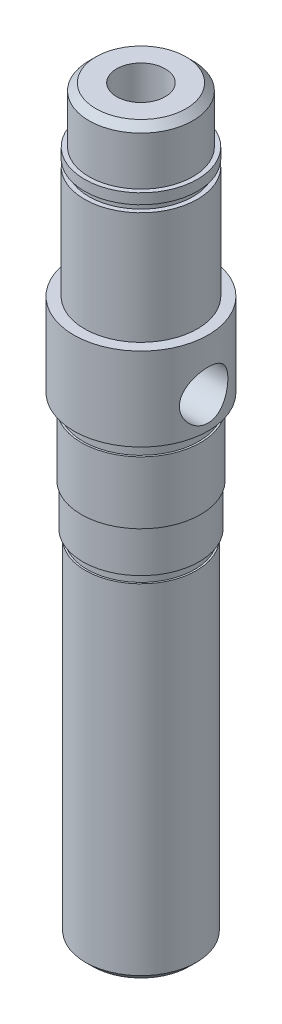
from build123d import *

# Parameters (mm, degrees)
ENL_V_START             = -5.5
ESQUISSE2_W             = 11.618950038
ESQUISSE2_H             = 44.4
ENL_V_MAT_EXTRU_1_DEPTH = 5.2
ENL_V_MAT_EXTRU_2_DEPTH = 10.7
ESQUISSE6_R             = 3.5
ENL_V_MAT_EXTRU_3_DEPTH = 120
CHANFREIN1_SIZE         = 1


with BuildPart() as part:
    # Esquisse1 → Révolution1 (revolve)
    with BuildSketch(Plane.XY):
        Polygon((0, 0), (-7, 0), (-8, 1), (-8, 50), (-7.75, 50), (-7.75, 51.3), (-8.4, 51.3), (-8.4, 57.3), (-8.6, 57.3), (-8.6, 66.3), (-8.33, 66.3), (-8.33, 68.3), (-9.7, 68.3), (-9.7, 80.3), (-8.15, 80.3), (-8.15, 96.5), (-7.5, 96.5), (-7.5, 97.5), (-8.15, 97.5), (-8.15, 99), (-7.5, 99), (-7.5, 106), (-6.5, 107), (0, 107), align=None)
    revolve(axis=Axis((0, 107, 0), (0, -1, 0)))

    # Esquisse2 → Enlèv. mat.-Extru.1 (cut, through all)
    with BuildSketch(Plane.XY.offset(ENL_V_START)):
        with Locations((0, 24.9)):
            Rectangle(ESQUISSE2_W, ESQUISSE2_H)
    extrude(amount=-ENL_V_MAT_EXTRU_1_DEPTH, mode=Mode.SUBTRACT)

    # Esquisse5 → Enlèv. mat.-Extru.2 (cut, through all)
    with BuildSketch(Plane(origin=(0, 0, 0), x_dir=(0, 0, -1), z_dir=(1, 0, 0))):
        with BuildLine():
            ThreePointArc((0, 76.3), (-3.5, 72.8), (0, 69.3))
            ThreePointArc((0, 69.3), (3.5, 72.8), (0, 76.3))
        make_face()
    extrude(amount=ENL_V_MAT_EXTRU_2_DEPTH, mode=Mode.SUBTRACT)

    # Esquisse6 → Enlèv. mat.-Extru.3 (cut)
    with BuildSketch(Plane.XZ):
        Circle(ESQUISSE6_R)
    extrude(amount=-ENL_V_MAT_EXTRU_3_DEPTH, mode=Mode.SUBTRACT)

    # Chanfrein1
    chanfrein1_edges = [part.edges().sort_by_distance(p)[0] for p in [
        (-3.5, 0, 0),
    ]]
    chamfer(chanfrein1_edges, length=CHANFREIN1_SIZE)


solid = part.part
